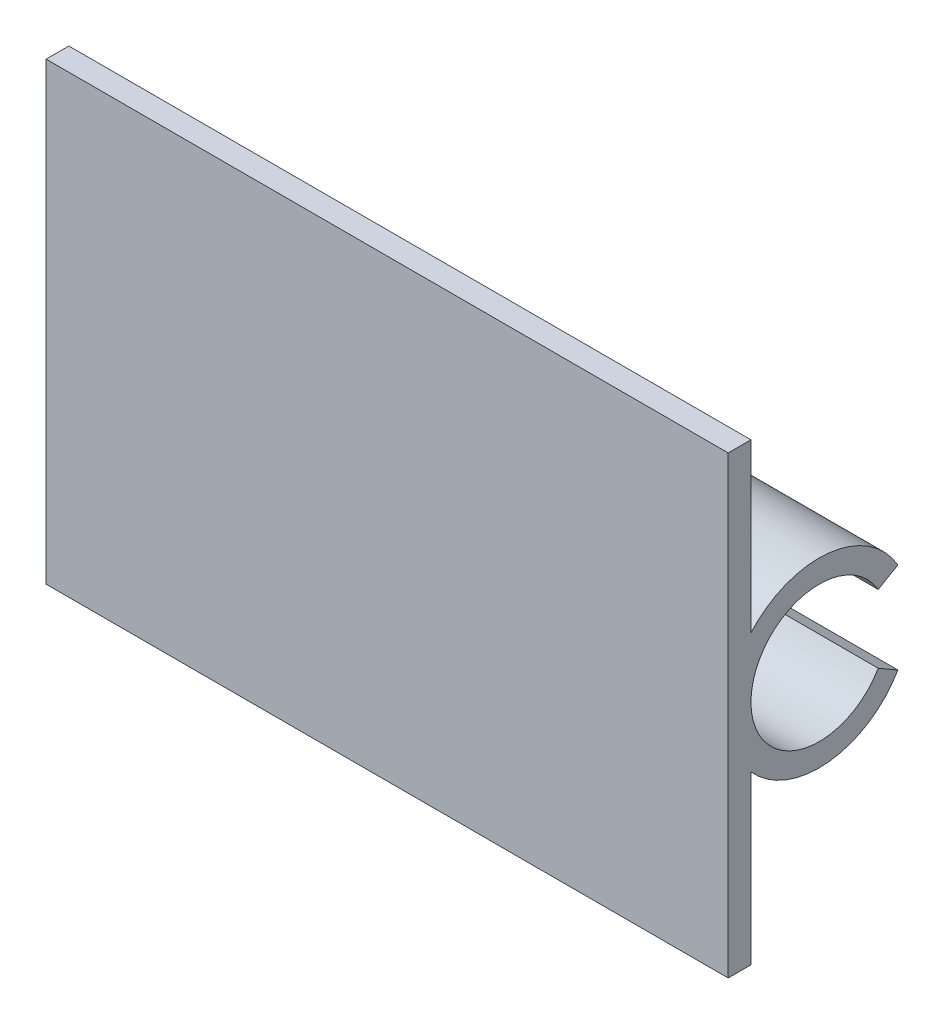
from build123d import *

# Parameters (mm, degrees)
SKETCH11_W          = 36
SKETCH11_H          = 12
BOSS_EXTRUDE3_DEPTH = 1.2
EXTRUDE_THIN2_START = 36
EXTRUDE_THIN2_DEPTH = 10


with BuildPart() as part:
    # Sketch11 → Boss-Extrude3 (new body)
    with BuildSketch(Plane.XY):
        with Locations((18, 6)):
            Rectangle(SKETCH11_W, SKETCH11_H)
    extrude(amount=BOSS_EXTRUDE3_DEPTH)

    # Sketch2 → Extrude-Thin2 (add)
    with BuildSketch(Plane(origin=(0, 0, 0), x_dir=(0, 0, -1), z_dir=(1, 0, 0)).offset(EXTRUDE_THIN2_START)):
        with BuildLine():
            ThreePointArc((0, 0), (2.668251438, 3.477332975), (6.717691454, 1.8))
            Line((6.717691454, 1.8), (7.756921938, 2.4))
            ThreePointArc((7.756921938, 2.4), (2.357668584, 4.636443966), (-1.2, 0))
            Line((-1.2, 0), (0, 0))
        make_face()
    extrude(amount=-EXTRUDE_THIN2_DEPTH)

    # Mirror1: part across plane


with BuildPart() as part_1:
    add(part.part)
    add(part.part.mirror(Plane.ZX))


solid = part_1.part
